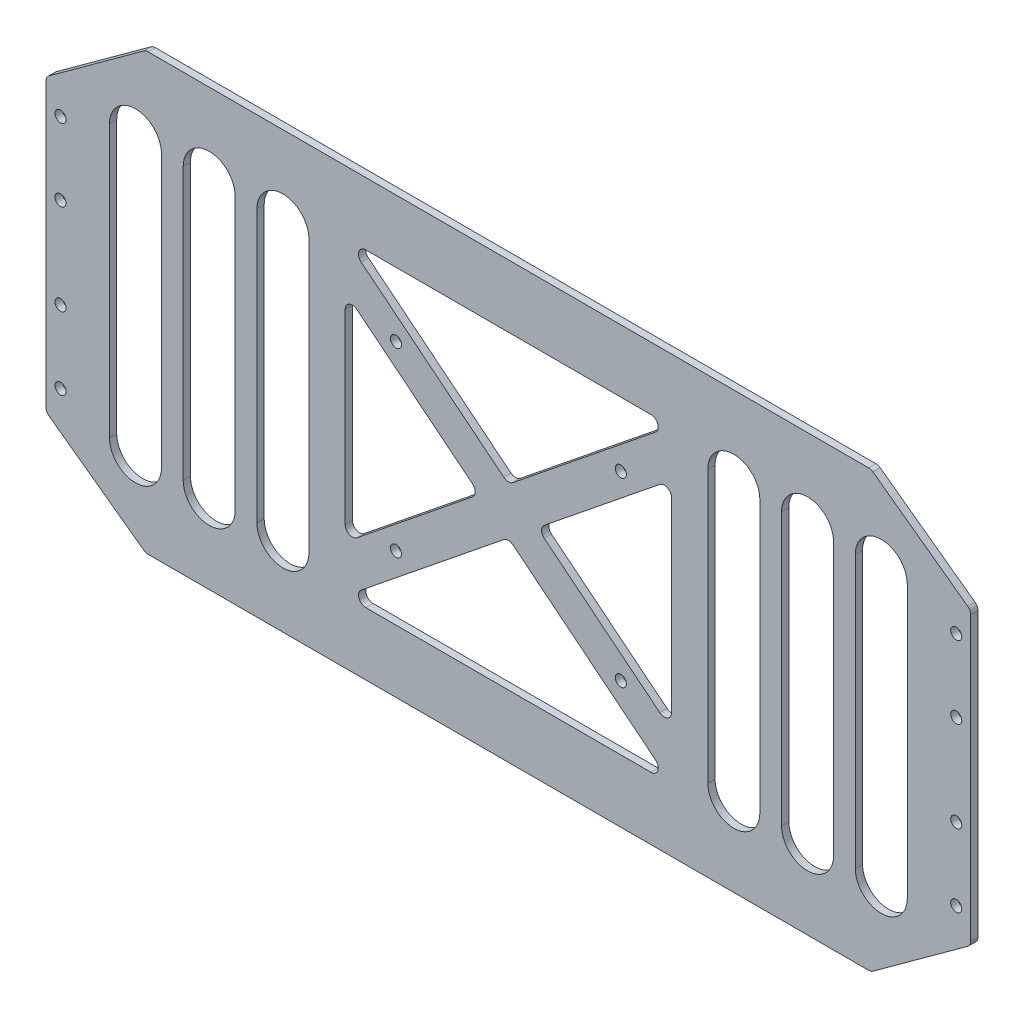
from build123d import *

# Parameters (mm, degrees)
EXTRUDE_1_DEPTH          = 2
SKETCH_2_R               = 1.525
CUT_EXTRUDE_1_DEPTH      = 1
CUT_EXTRUDE_1_DEPTH_BACK = 3
CUT_EXTRUDE_START        = -3
SKETCH_3_R               = 1.525
CUT_EXTRUDE_2_DEPTH      = 4
CUT_EXTRUDE_3_DEPTH      = 1
CUT_EXTRUDE_3_DEPTH_BACK = 3
FILLET_1_R               = 2
CUT_EXTRUDE_4_DEPTH      = 4
FILLET_2_R               = 2


with BuildPart() as part:
    # 草图1 → 凸台-拉伸1 (new body)
    with BuildSketch(Plane.XY):
        Polygon((-100, 60), (-127.5, 40), (-127.5, -40), (-100, -60), (100, -60), (127.5, -40), (127.5, 40), (100, 60), align=None)
    extrude(amount=EXTRUDE_1_DEPTH)

    # 草图2 → 切除-拉伸1 (cut, two sides)
    with BuildSketch(Plane(origin=(0, 0, 0), x_dir=(-1, 0, 0), z_dir=(0, 0, -1))) as cut_extrude_1_sk:
        with Locations((31, -25)):
            Circle(SKETCH_2_R)
        with Locations((-31, -25)):
            Circle(SKETCH_2_R)
        with Locations((-31, 25)):
            Circle(SKETCH_2_R)
        with Locations((31, 25)):
            Circle(SKETCH_2_R)
    extrude(amount=CUT_EXTRUDE_1_DEPTH, mode=Mode.SUBTRACT)
    extrude(cut_extrude_1_sk.sketch, amount=-CUT_EXTRUDE_1_DEPTH_BACK, mode=Mode.SUBTRACT)

    # 草图3 → 切除-拉伸2 (cut)
    with BuildSketch(Plane.XY.offset(2).offset(CUT_EXTRUDE_START)):
        with Locations((-123.5, -32.5)):
            Circle(SKETCH_3_R)
        with Locations((-123.5, -12.5)):
            Circle(SKETCH_3_R)
        with Locations((-123.5, 12.5)):
            Circle(SKETCH_3_R)
        with Locations((-123.5, 32.5)):
            Circle(SKETCH_3_R)
    cut_extrude_2 = extrude(amount=CUT_EXTRUDE_2_DEPTH, mode=Mode.SUBTRACT)

    # 镜向1: 切除-拉伸2 across plane
    add(cut_extrude_2.mirror(Plane(origin=(0, 0, 0), x_dir=(0, 0, 1), z_dir=(1, 0, 0))), mode=Mode.SUBTRACT)

    # 草图4 → 切除-拉伸3 (cut, two sides)
    with BuildSketch(Plane.XY.offset(2)) as cut_extrude_3_sk:
        Polygon((-45, 42.713647662), (45, 42.713647662), (0, 6.423325081), align=None)
        Polygon((-45, 29.866997499), (-45, -29.866997499), (-7.964923101, 0), align=None)
        Polygon((-45, -42.713647662), (45, -42.713647662), (0, -6.423325081), align=None)
        Polygon((45, -29.866997499), (7.964923101, 0), (45, 29.866997499), align=None)
    extrude(amount=CUT_EXTRUDE_3_DEPTH, mode=Mode.SUBTRACT)
    extrude(cut_extrude_3_sk.sketch, amount=-CUT_EXTRUDE_3_DEPTH_BACK, mode=Mode.SUBTRACT)

    # 圆角1
    fillet_1_edges = [part.edges().sort_by_distance(p)[0] for p in [
        (-45, 29.866997499, 1),
        (-7.964923101, 0, 1),
        (-45, -29.866997499, 1),
        (45, 29.866997499, 1),
        (45, -29.866997499, 1),
        (7.964923101, 0, 1),
        (0, 6.423325081, 1),
        (-45, 42.713647662, 1),
        (45, 42.713647662, 1),
        (-45, -42.713647662, 1),
        (0, -6.423325081, 1),
        (45, -42.713647662, 1),
    ]]
    fillet(fillet_1_edges, radius=FILLET_1_R)

    # 草图5 → 切除-拉伸4 (cut)
    with BuildSketch(Plane.XY.offset(2).offset(CUT_EXTRUDE_START)):
        with BuildLine():
            Line((-110, -37.5), (-110, 37.5))
            ThreePointArc((-110, 37.5), (-102.833333333, 44.666666667), (-95.666666667, 37.5))
            Line((-95.666666667, 37.5), (-95.666666667, -37.5))
            ThreePointArc((-95.666666667, -37.5), (-102.833333333, -44.666666667), (-110, -37.5))
        make_face()
        with BuildLine():
            Line((-75.333333333, 37.5), (-75.333333333, -37.5))
            ThreePointArc((-75.333333333, -37.5), (-82.5, -44.666666667), (-89.666666667, -37.5))
            Line((-89.666666667, -37.5), (-89.666666667, 37.5))
            ThreePointArc((-89.666666667, 37.5), (-82.5, 44.666666667), (-75.333333333, 37.5))
        make_face()
        with BuildLine():
            Line((-55, 37.5), (-55, -37.5))
            ThreePointArc((-55, -37.5), (-62.166666667, -44.666666667), (-69.333333333, -37.5))
            Line((-69.333333333, -37.5), (-69.333333333, 37.5))
            ThreePointArc((-69.333333333, 37.5), (-62.166666667, 44.666666667), (-55, 37.5))
        make_face()
    cut_extrude_4 = extrude(amount=CUT_EXTRUDE_4_DEPTH, mode=Mode.SUBTRACT)

    # 镜向2: 切除-拉伸4 across plane
    add(cut_extrude_4.mirror(Plane(origin=(0, 0, 0), x_dir=(0, 0, 1), z_dir=(1, 0, 0))), mode=Mode.SUBTRACT)

    # 圆角2
    fillet_2_edges = [part.edges().sort_by_distance(p)[0] for p in [
        (127.5, 40, 1),
        (127.5, -40, 1),
        (100, -60, 1),
        (-100, -60, 1),
        (-127.5, -40, 1),
        (-127.5, 40, 1),
        (-100, 60, 1),
        (100, 60, 1),
    ]]
    fillet(fillet_2_edges, radius=FILLET_2_R)


solid = part.part
